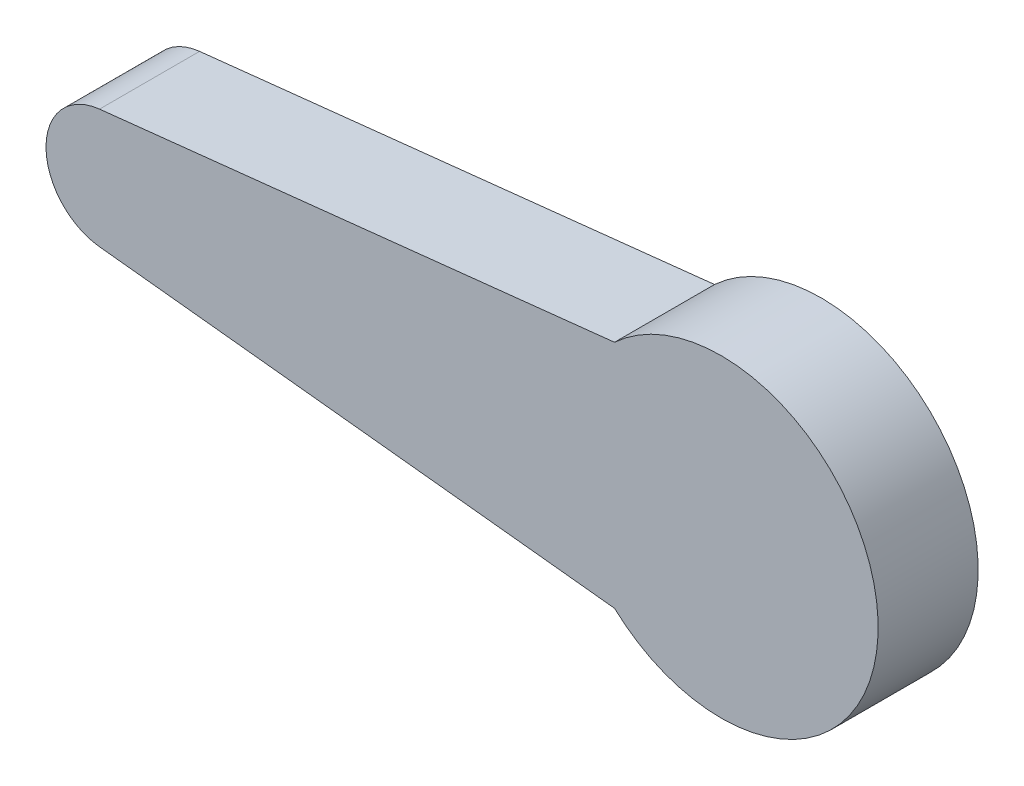
from build123d import *

# Parameters (mm, degrees)
BOSS_EXTRUDE6_DEPTH = 4
CUT_EXTRUDE1_DEPTH  = 2


with BuildPart() as part:
    # Sketch2 → Boss-Extrude6 (new body)
    with BuildSketch(Plane.XY):
        with BuildLine():
            Line((7.936945185, 4.607509822), (-12.657523049, 2.384648727))
            ThreePointArc((-12.657523049, 2.384648727), (-14.798635322, 0), (-12.657523049, -2.384648727))
            Line((-12.657523049, -2.384648727), (7.936945185, -4.607509822))
            ThreePointArc((7.936945185, -4.607509822), (18.479455181, 0), (7.936945185, 4.607509822))
        make_face()
    extrude(amount=BOSS_EXTRUDE6_DEPTH)

    # Sketch1 → Cut-Extrude1 (cut)
    with BuildSketch(Plane.XY):
        with BuildLine():
            Line((-2.308259951, 2.498066053), (9.375044145, 3.190055955))
            add(Edge.make_bspline(
                [(9.375044145, 3.190055955), (9.743762717, 3.535051607), (10.542113364, 3.885379294), (11.739855888, 4.053778423), (12.781606273, 3.904003548), (13.647647588, 3.58835165), (14.172524986, 3.123610305), (14.749448402, 2.727996587), (15.239395752, 2.01553181), (15.653528757, 1.050879588), (15.788992815, -0.000691818), (15.651665108, -1.048112313), (15.246850359, -2.025217286), (14.603250264, -2.863967716), (13.764299096, -3.507779486), (12.787785525, -3.91194775), (11.73820132, -4.051651269), (10.542857019, -3.886335356), (9.743600409, -3.534842939), (9.375044145, -3.190055955)],
                knots=[0, 0, 0, 0, 0.085136877, 0.144403023, 0.203669169, 0.262935434, 0.297502717, 0.322201499, 0.3814676, 0.440733879, 0.5, 0.559266121, 0.6185324, 0.677798501, 0.737064566, 0.796330831, 0.855596977, 0.914863123, 1, 1, 1, 1], degree=3))
            Line((9.375044145, -3.190055955), (-2.308259951, -2.498066053))
            add(Edge.make_bspline(
                [(-2.308259951, -2.498066053), (-2.730270965, -2.498681523), (-3.365255191, -2.317767142), (-4.051947117, -1.791219452), (-4.45450445, -1.266528616), (-4.707556493, -0.655614107), (-4.793872131, 0), (-4.707556493, 0.655614107), (-4.45450445, 1.266528616), (-4.051947117, 1.791219452), (-3.365255191, 2.317767142), (-2.730270965, 2.498681523), (-2.308259951, 2.498066053)],
                knots=[0, 0, 0, 0, 0.162547316, 0.2469105, 0.331273485, 0.415637006, 0.5, 0.584362994, 0.668726515, 0.7530895, 0.837452684, 1, 1, 1, 1], degree=3))
        make_face()
    extrude(amount=CUT_EXTRUDE1_DEPTH, mode=Mode.SUBTRACT)


solid = part.part
